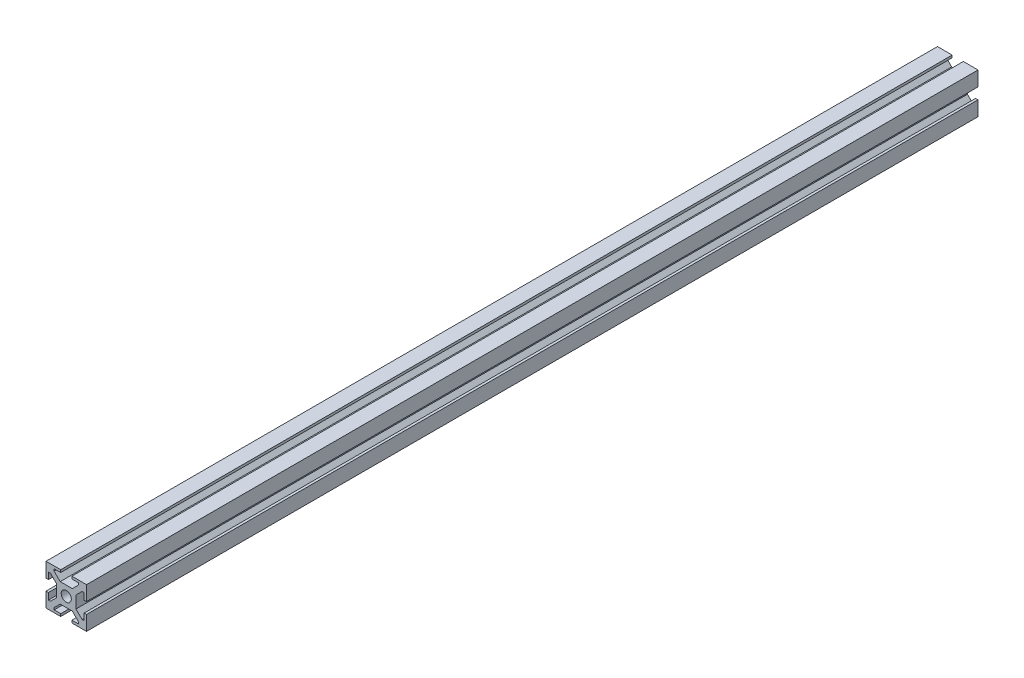
from build123d import *

# Parameters (mm, degrees)
ESQUISSE1_W             = 20
ESQUISSE1_H             = 20
BOSS_EXTRU_1_DEPTH      = 440
ESQUISSE2_W             = 1.2
ESQUISSE2_H             = 5.5
ESQUISSE2_W_2           = 5.5
ESQUISSE2_H_2           = 1.2
ENL_V_MAT_EXTRU_1_DEPTH = 441
ENL_V_MAT_EXTRU_2_DEPTH = 441
ESQUISSE4_R             = 2.5
ENL_V_MAT_EXTRU_3_DEPTH = 441


with BuildPart() as part:
    # Esquisse1 → Boss.-Extru.1 (new body)
    with BuildSketch(Plane.XY):
        with Locations((-12.505109137, -9.909560068)):
            Rectangle(ESQUISSE1_W, ESQUISSE1_H)
    extrude(amount=BOSS_EXTRU_1_DEPTH)

    # Esquisse2 → Enlèv. mat.-Extru.1 (cut, through all)
    with BuildSketch(Plane.XY.offset(440)):
        with Locations((-21.905109137, -9.909560068)):
            Rectangle(ESQUISSE2_W, ESQUISSE2_H)
        with Locations((-12.505109137, -0.509560068)):
            Rectangle(ESQUISSE2_W_2, ESQUISSE2_H_2)
        with Locations((-3.105109137, -9.909560068)):
            Rectangle(ESQUISSE2_W, ESQUISSE2_H)
        with Locations((-12.505109137, -19.309560068)):
            Rectangle(ESQUISSE2_W_2, ESQUISSE2_H_2)
    extrude(amount=-ENL_V_MAT_EXTRU_1_DEPTH, mode=Mode.SUBTRACT)

    # Esquisse3 → Enlèv. mat.-Extru.2 (cut, through all)
    with BuildSketch(Plane.XY.offset(440)):
        Polygon((-21.305109137, -15.909560068), (-20.305109137, -15.909560068), (-17.305109137, -12.909560068), (-17.305109137, -6.909560068), (-20.305109137, -3.909560068), (-21.305109137, -3.909560068), align=None)
        Polygon((-18.505109137, -1.109560068), (-6.505109137, -1.109560068), (-6.505109137, -2.109560068), (-9.505109137, -5.109560068), (-15.505109137, -5.109560068), (-18.505109137, -2.109560068), align=None)
        Polygon((-3.705109137, -3.909560068), (-4.705109137, -3.909560068), (-7.705109137, -6.909560068), (-7.705109137, -12.909560068), (-4.705109137, -15.909560068), (-3.705109137, -15.909560068), align=None)
        Polygon((-6.505109137, -18.709560068), (-18.505109137, -18.709560068), (-18.505109137, -17.709560068), (-15.505109137, -14.709560068), (-9.505109137, -14.709560068), (-6.505109137, -17.709560068), align=None)
    extrude(amount=-ENL_V_MAT_EXTRU_2_DEPTH, mode=Mode.SUBTRACT)

    # Esquisse4 → Enlèv. mat.-Extru.3 (cut, through all)
    with BuildSketch(Plane.XY.offset(440)):
        with Locations((-12.505109137, -9.909560068)):
            Circle(ESQUISSE4_R)
    extrude(amount=-ENL_V_MAT_EXTRU_3_DEPTH, mode=Mode.SUBTRACT)


solid = part.part
